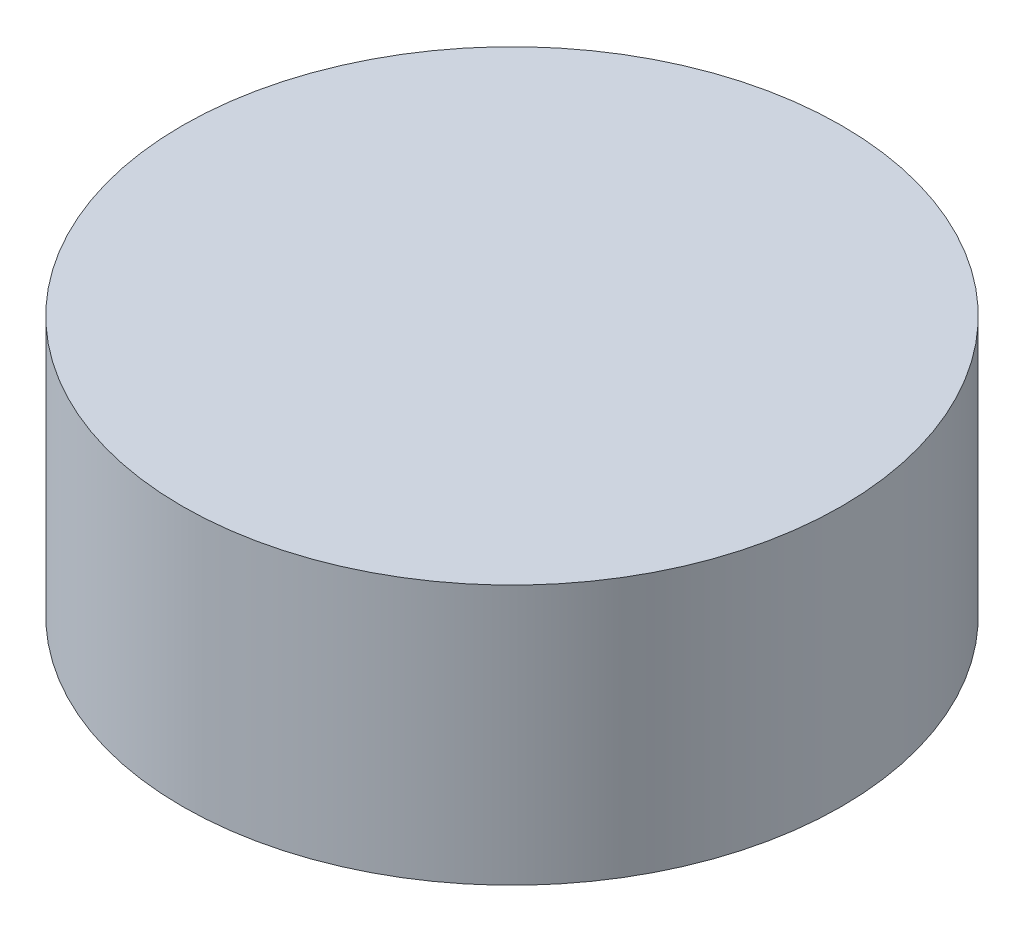
from build123d import *

# Parameters (mm, degrees)
SKETCH1_R           = 52
BOSS_EXTRUDE1_DEPTH = 41


with BuildPart() as part:
    # Sketch1 → Boss-Extrude1 (new body)
    with BuildSketch(Plane(origin=(0, 0, 0), x_dir=(1, 0, 0), z_dir=(0, 1, 0))):
        Circle(SKETCH1_R)
    extrude(amount=BOSS_EXTRUDE1_DEPTH)


solid = part.part
